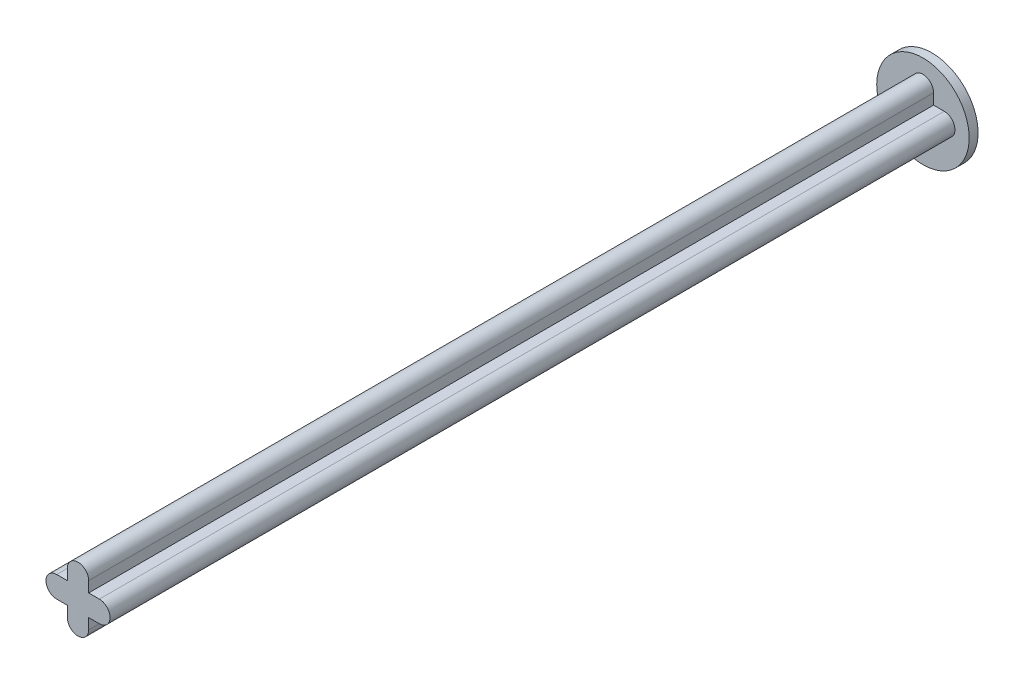
from build123d import *

# Parameters (mm, degrees)
BOSS_EXTRUDE1_DEPTH = 60.96
SKETCH2_R           = 3.302
BOSS_EXTRUDE2_DEPTH = 0.635


with BuildPart() as part:
    # Sketch1 → Boss-Extrude1 (new body)
    with BuildSketch(Plane.XY):
        with BuildLine():
            Line((0.762, 0.762), (0, 0.762))
            ThreePointArc((0, 0.762), (-0.762, 0), (0, -0.762))
            Line((0, -0.762), (0.762, -0.762))
            Line((0.762, -0.762), (0.762, -1.524))
            ThreePointArc((0.762, -1.524), (1.524, -2.286), (2.286, -1.524))
            Line((2.286, -1.524), (2.286, -0.762))
            Line((2.286, -0.762), (3.048, -0.762))
            ThreePointArc((3.048, -0.762), (3.81, 0), (3.048, 0.762))
            Line((3.048, 0.762), (2.286, 0.762))
            Line((2.286, 0.762), (2.286, 1.524))
            ThreePointArc((2.286, 1.524), (1.524, 2.286), (0.762, 1.524))
            Line((0.762, 1.524), (0.762, 0.762))
        make_face()
    extrude(amount=BOSS_EXTRUDE1_DEPTH)

    # Sketch2 → Boss-Extrude2 (add)
    with BuildSketch(Plane(origin=(0, 0, 0), x_dir=(-1, 0, 0), z_dir=(0, 0, -1))):
        with Locations((-1.524, 0)):
            Circle(SKETCH2_R)
    extrude(amount=-BOSS_EXTRUDE2_DEPTH)


solid = part.part
